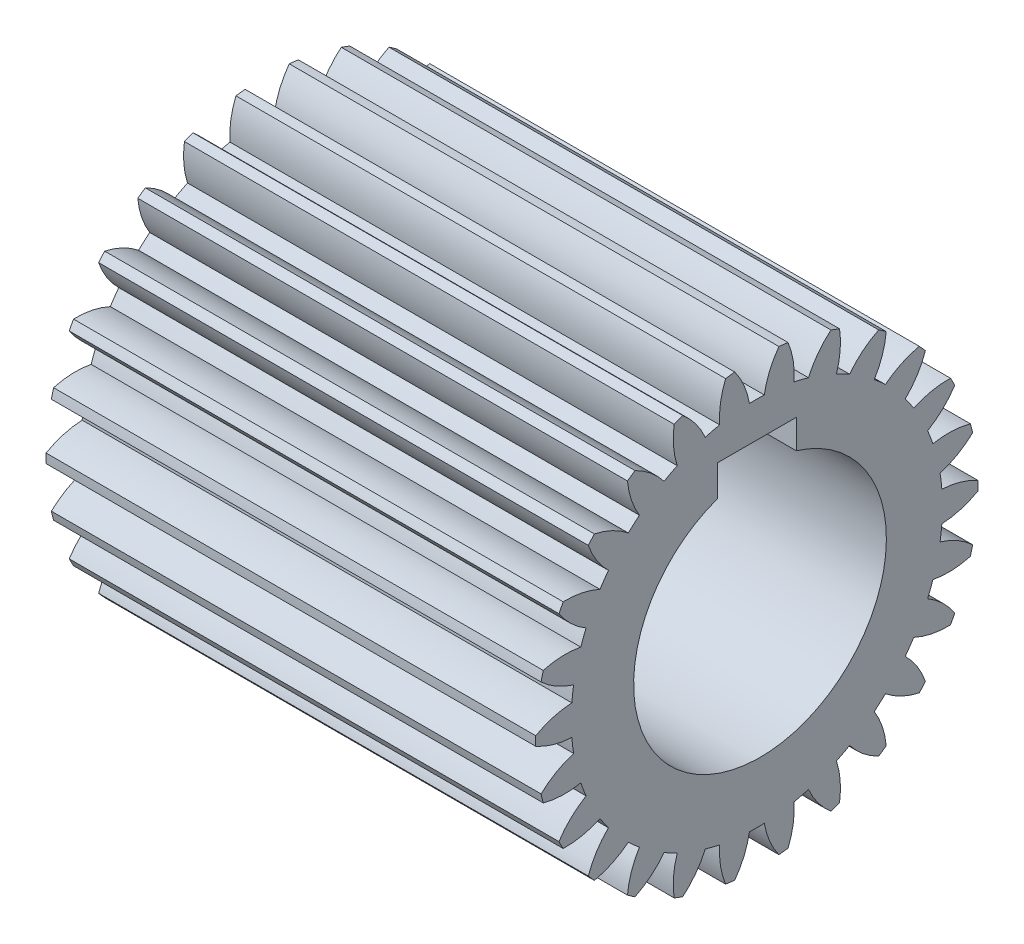
from build123d import *

# Parameters (mm, degrees)
BASPROSKE_W        = 62
BASPROSKE_H        = 28
TOOTHCUT_DEPTH     = 74.566296631
TEETHCUTS_COUNT    = 26
TEETHCUTS_ANGLE    = 346.153846154
BORSKE_R           = 0.4
BORE_DEPTH         = 62.0000508
CUT_EXTRUDE1_DEPTH = 74.51313205


with BuildPart() as part:
    # BasProSke → Base-Revolve (revolve)
    with BuildSketch(Plane(origin=(0, 0, 0), x_dir=(1, 0, 0), z_dir=(0, 1, 0)), mode=Mode.PRIVATE) as base_revolve_sk:
        with Locations((31, 14)):
            Rectangle(BASPROSKE_W, BASPROSKE_H)
    revolve(base_revolve_sk.sketch.rotate(Axis((-10, 0, 0), (1, 0, 0)), 180), axis=Axis((-10, 0, 0), (1, 0, 0)))

    # TooCutSke → ToothCut (cut, through all)
    with BuildSketch(Plane(origin=(0, 0, 0), x_dir=(0, 0, -1), z_dir=(1, 0, 0))):
        with BuildLine():
            ThreePointArc((0.939856059, 23.480197435), (0, 23.499), (-0.939856059, 23.480197435))
            ThreePointArc((-0.939856059, 23.480197435), (-1.620069556, 25.791248201), (-2.813767052, 27.883790276))
            ThreePointArc((-2.813767052, 27.883790276), (0, 28.0254), (2.813767052, 27.883790276))
            ThreePointArc((2.813767052, 27.883790276), (1.620069556, 25.791248201), (0.939856059, 23.480197435))
        make_face()
    toothcut = extrude(amount=TOOTHCUT_DEPTH, mode=Mode.SUBTRACT)

    # TeethCuts: ToothCut ×26 about axis
    teethcuts_axis = Axis((-10, 0, 0), (1, 0, 0))
    for i in range(1, TEETHCUTS_COUNT):
        add(toothcut.rotate(teethcuts_axis, i * TEETHCUTS_ANGLE / (TEETHCUTS_COUNT - 1)), mode=Mode.SUBTRACT)

    # BorSke → Bore (cut, symmetric)
    with BuildSketch(Plane(origin=(0, 0, 0), x_dir=(0, 0, -1), z_dir=(1, 0, 0))):
        with Locations(Location((0, 0, 0), (0, 0, 180))):
            Circle(BORSKE_R)
    extrude(amount=BORE_DEPTH, both=True, mode=Mode.SUBTRACT)

    # Sketch1 → Cut-Extrude1 (cut, through all)
    with BuildSketch(Plane(origin=(62, 0, 0), x_dir=(0, 0, -1), z_dir=(1, 0, 0))):
        with BuildLine():
            Line((-5, 19), (5, 19))
            Line((5, 19), (5, 15.324490204))
            ThreePointArc((5, 15.324490204), (0.82110488, -15.994457499), (-5, 15.061208451))
            Line((-5, 15.061208451), (-5, 19))
        make_face()
    extrude(amount=-CUT_EXTRUDE1_DEPTH, mode=Mode.SUBTRACT)


solid = part.part
